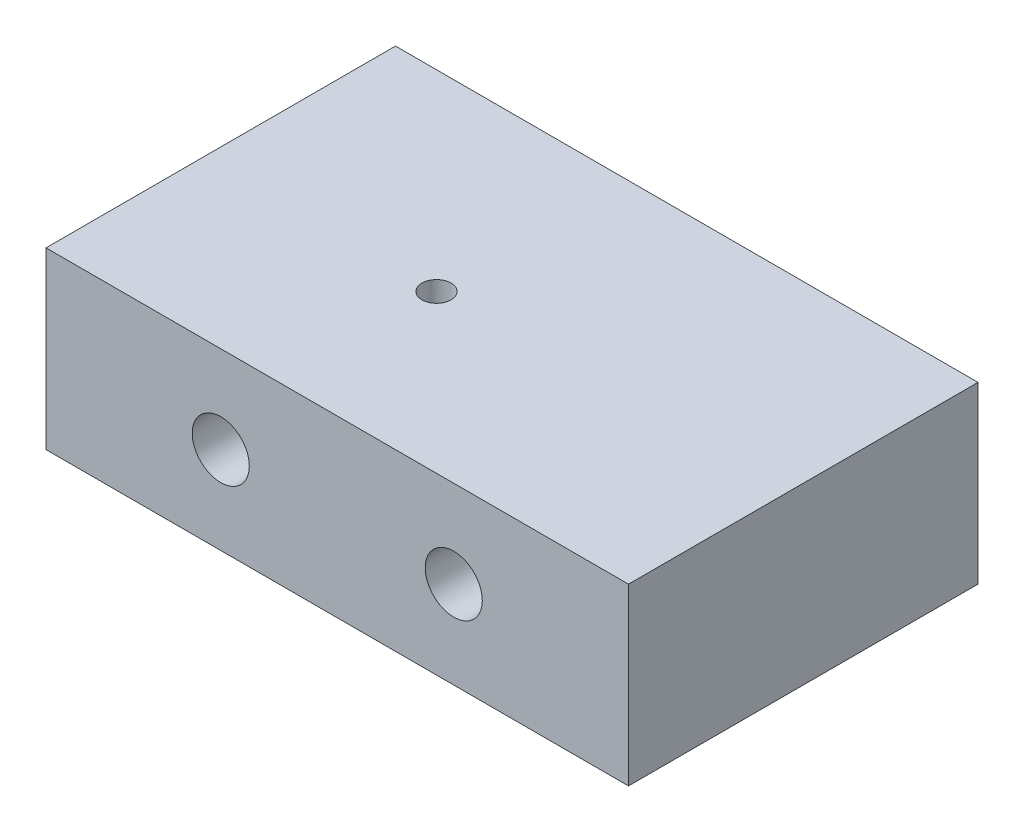
from build123d import *

# Parameters (mm, degrees)
SKETCH1_W           = 50
SKETCH1_H           = 30
BOSS_EXTRUDE1_DEPTH = 15
SKETCH2_R           = 2.45
CUT_EXTRUDE1_DEPTH  = 31
SKETCH3_R           = 1.25
CUT_EXTRUDE2_DEPTH  = 16


with BuildPart() as part:
    # Sketch1 → Boss-Extrude1 (new body)
    with BuildSketch(Plane(origin=(0, 0, 0), x_dir=(1, 0, 0), z_dir=(0, 1, 0))):
        with Locations((25, 15)):
            Rectangle(SKETCH1_W, SKETCH1_H)
    extrude(amount=BOSS_EXTRUDE1_DEPTH)

    # Sketch2 → Cut-Extrude1 (cut, through all)
    with BuildSketch(Plane.XY):
        with Locations((35, 7.5)):
            Circle(SKETCH2_R)
        with Locations((15, 7.5)):
            Circle(SKETCH2_R)
    extrude(amount=-CUT_EXTRUDE1_DEPTH, mode=Mode.SUBTRACT)

    # Sketch3 → Cut-Extrude2 (cut, through all)
    with BuildSketch(Plane(origin=(0, 15, 0), x_dir=(1, 0, 0), z_dir=(0, 1, 0))):
        with Locations((20, 13.518993942)):
            Circle(SKETCH3_R)
    extrude(amount=-CUT_EXTRUDE2_DEPTH, mode=Mode.SUBTRACT)


solid = part.part
